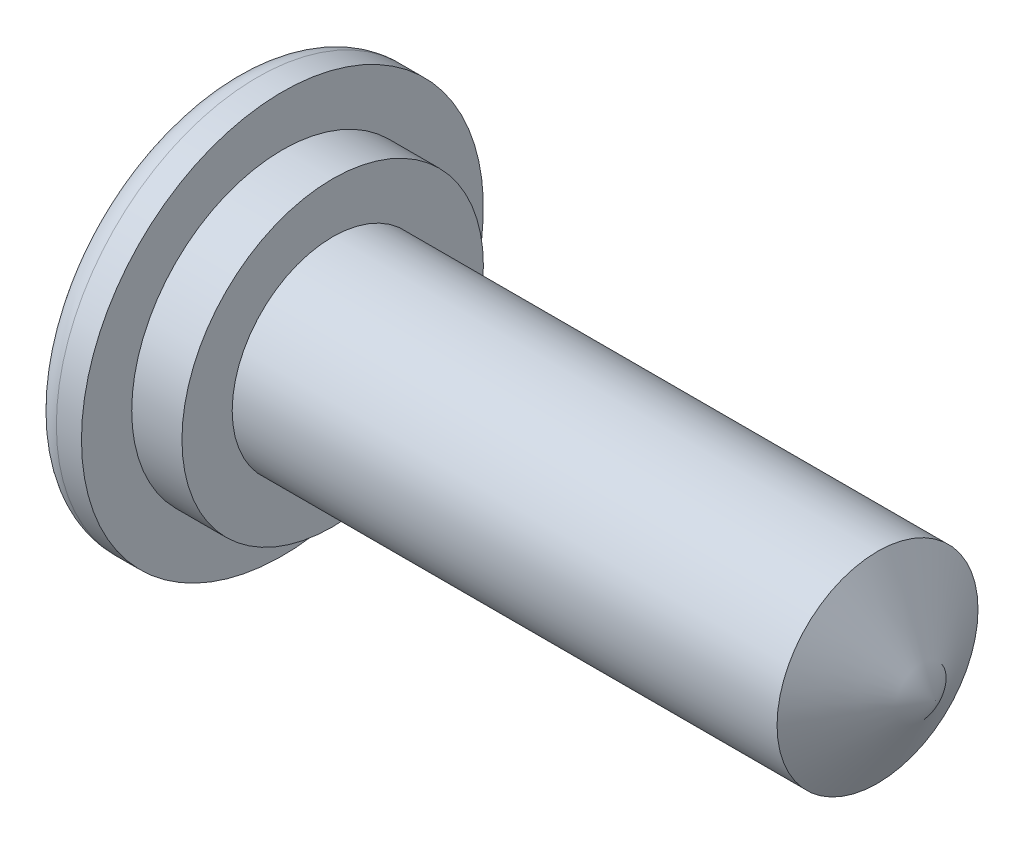
from build123d import *


with BuildPart() as part:
    # Esquisse1 → Révolution1 (revolve)
    with BuildSketch(Plane.XY):
        with BuildLine():
            Line((0, 3), (1, 3))
            Line((1, 3), (1, 2))
            Line((1, 2), (11.845299462, 2))
            Line((11.845299462, 2), (13, 0))
            Line((13, 0), (1.154700538, 0))
            Line((1.154700538, 0), (0, 2))
            Line((0, 2), (-0.5, 2))
            ThreePointArc((-0.5, 2), (-0.853553391, 2.146446609), (-1, 2.5))
            Line((-1, 2.5), (-1, 3.5))
            ThreePointArc((-1, 3.5), (-0.853553391, 3.853553391), (-0.5, 4))
            Line((-0.5, 4), (0, 4))
            Line((0, 4), (0, 3))
        make_face()
    revolve(axis=Axis((-8.537570942, 0, 0), (1, 0, 0)))


solid = part.part
